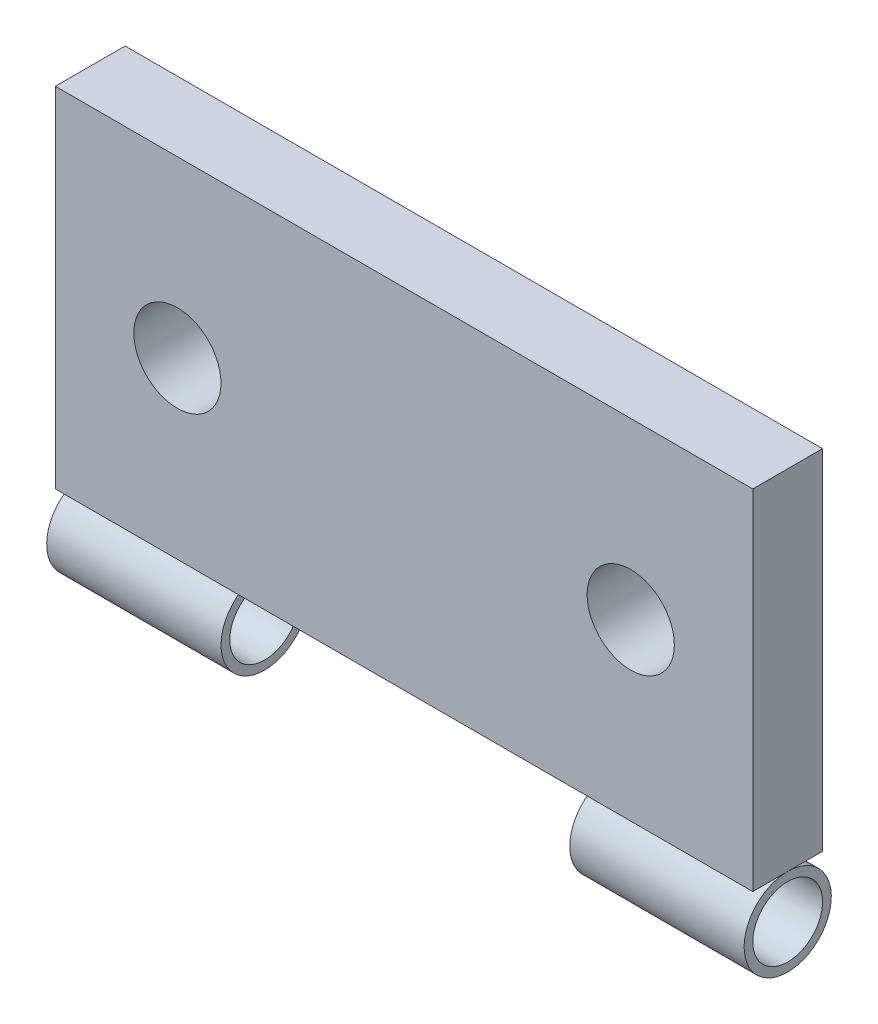
from build123d import *

# Parameters (mm, degrees)
SKETCH1_W           = 40
SKETCH1_H           = 20
SKETCH1_R           = 2.5
BOSS_EXTRUDE1_DEPTH = 2
SKETCH3_R           = 2.5
SKETCH3_R_2         = 2
BOSS_EXTRUDE2_DEPTH = 40
SKETCH4_W           = 20
SKETCH4_H           = 5.18072448
CUT_EXTRUDE1_DEPTH  = 5


with BuildPart() as part:
    # Sketch1 → Boss-Extrude1 (new body, symmetric)
    with BuildSketch(Plane.XY):
        Rectangle(SKETCH1_W, SKETCH1_H)
        with Locations((-13, 0)):
            Circle(SKETCH1_R, mode=Mode.SUBTRACT)
        with Locations((13, 0)):
            Circle(SKETCH1_R, mode=Mode.SUBTRACT)
    extrude(amount=BOSS_EXTRUDE1_DEPTH, both=True)


with BuildPart() as body_2:
    # Sketch3 → Boss-Extrude2 (new body)
    with BuildSketch(Plane.ZY.offset(20)):
        with Locations((-0.003340528, -12.5)):
            Circle(SKETCH3_R)
        with Locations((-0.003340528, -12.5)):
            Circle(SKETCH3_R_2, mode=Mode.SUBTRACT)
    extrude(amount=-BOSS_EXTRUDE2_DEPTH)

    # Sketch4 → Cut-Extrude1 (cut, symmetric)
    with BuildSketch(Plane.XY.offset(2)):
        with Locations((0, -12.59036224)):
            Rectangle(SKETCH4_W, SKETCH4_H)
    extrude(amount=CUT_EXTRUDE1_DEPTH, both=True, mode=Mode.SUBTRACT)


solid = Compound([part.part, body_2.part])
